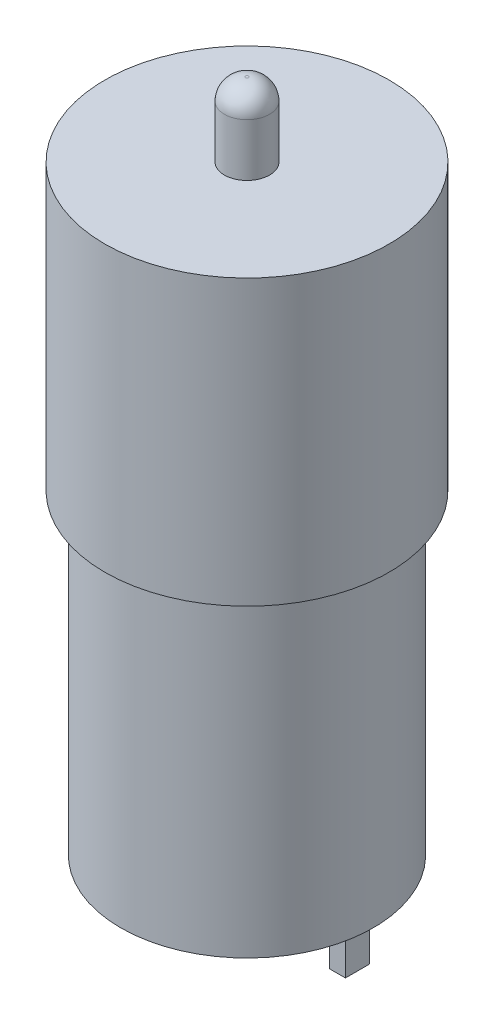
from build123d import *

# Parameters (mm, degrees)
SKETCH1_R           = 12
BOSS_EXTRUDE1_DEPTH = 30
SKETCH2_R           = 13.5
BOSS_EXTRUDE2_DEPTH = 27
SKETCH3_R           = 2.15
BOSS_EXTRUDE3_DEPTH = 7
FILLET1_R           = 2
SKETCH4_R           = 3.215
BOSS_EXTRUDE4_DEPTH = 2.32
FILLET2_R           = 2
SKETCH5_W           = 1.5
SKETCH5_H           = 2.3
BOSS_EXTRUDE5_DEPTH = 4.3


with BuildPart() as part:
    # Sketch1 → Boss-Extrude1 (new body)
    with BuildSketch(Plane(origin=(0, 0, 0), x_dir=(1, 0, 0), z_dir=(0, 1, 0))):
        Circle(SKETCH1_R)
    extrude(amount=BOSS_EXTRUDE1_DEPTH)

    # Sketch2 → Boss-Extrude2 (add)
    with BuildSketch(Plane(origin=(0, 30, 0), x_dir=(1, 0, 0), z_dir=(0, 1, 0))):
        Circle(SKETCH2_R)
    extrude(amount=BOSS_EXTRUDE2_DEPTH)

    # Sketch3 → Boss-Extrude3 (add)
    with BuildSketch(Plane(origin=(0, 57, 0), x_dir=(1, 0, 0), z_dir=(0, 1, 0))):
        Circle(SKETCH3_R)
    extrude(amount=BOSS_EXTRUDE3_DEPTH)

    # Fillet1
    fillet1_edges = [part.edges().sort_by_distance(p)[0] for p in [
        (-2.15, 64, 0),
    ]]
    fillet(fillet1_edges, radius=FILLET1_R)

    # Sketch4 → Boss-Extrude4 (add)
    with BuildSketch(Plane.XZ):
        Circle(SKETCH4_R)
    extrude(amount=BOSS_EXTRUDE4_DEPTH)

    # Fillet2
    fillet2_edges = [part.edges().sort_by_distance(p)[0] for p in [
        (-3.215, -2.32, 0),
    ]]
    fillet(fillet2_edges, radius=FILLET2_R)

    # Sketch5 → Boss-Extrude5 (add)
    with BuildSketch(Plane.XZ):
        with Locations((9.75, 0)):
            Rectangle(SKETCH5_W, SKETCH5_H)
        with Locations((-9.75, 0)):
            Rectangle(SKETCH5_W, SKETCH5_H)
    extrude(amount=BOSS_EXTRUDE5_DEPTH)


solid = part.part
